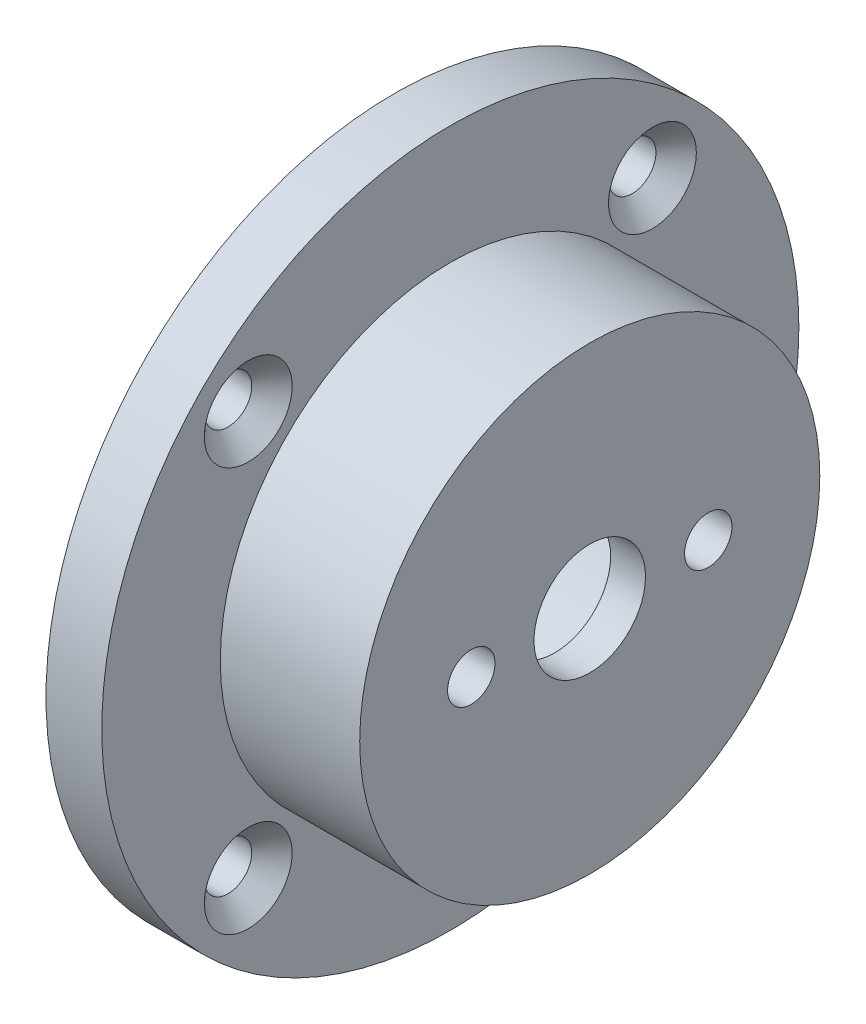
from build123d import *

# Parameters (mm, degrees)
SKETCH1_R                                       = 25
BOSS_EXTRUDE1_DEPTH                             = 4
SKETCH2_R                                       = 16.5
BOSS_EXTRUDE2_DEPTH                             = 10
SKETCH3_R                                       = 12.5
CUT_EXTRUDE1_DEPTH                              = 11.5
SKETCH4_R                                       = 4
CUT_EXTRUDE2_DEPTH                              = 4
M3_CLEARANCE_HOLE1_D                            = 3.4
M3_CLEARANCE_HOLE1_DEPTH                        = 10
CSK_FOR_M3_FLAT_HEAD_MACHINE_SCREW1_D           = 3.4
CSK_FOR_M3_FLAT_HEAD_MACHINE_SCREW1_CSINK_D     = 6.3
CSK_FOR_M3_FLAT_HEAD_MACHINE_SCREW1_CSINK_ANGLE = 90
CIRPATTERN1_COUNT                               = 4
SKETCH10_R                                      = 13.125
CUT_EXTRUDE3_DEPTH                              = 11.5


with BuildPart() as part:
    # Sketch1 → Boss-Extrude1 (new body)
    with BuildSketch(Plane(origin=(0, 0, 0), x_dir=(0, 0, -1), z_dir=(1, 0, 0))):
        Circle(SKETCH1_R)
    extrude(amount=BOSS_EXTRUDE1_DEPTH)

    # Sketch2 → Boss-Extrude2 (add)
    with BuildSketch(Plane(origin=(4, 0, 0), x_dir=(0, 0, -1), z_dir=(1, 0, 0))):
        Circle(SKETCH2_R)
    extrude(amount=BOSS_EXTRUDE2_DEPTH)

    # Sketch3 → Cut-Extrude1 (cut)
    with BuildSketch(Plane.ZY):
        Circle(SKETCH3_R)
    extrude(amount=-CUT_EXTRUDE1_DEPTH, mode=Mode.SUBTRACT)

    # Sketch4 → Cut-Extrude2 (cut)
    with BuildSketch(Plane(origin=(14, 0, 0), x_dir=(0, 0, -1), z_dir=(1, 0, 0))):
        Circle(SKETCH4_R)
    extrude(amount=-CUT_EXTRUDE2_DEPTH, mode=Mode.SUBTRACT)

    # M3 Clearance Hole1
    with Locations(Plane(origin=(14, 0, 0), x_dir=(0, 0, -1), z_dir=(1, 0, 0))):
        with Locations((8.5, 0), (-8.5, 0)):
            Hole(M3_CLEARANCE_HOLE1_D / 2, depth=M3_CLEARANCE_HOLE1_DEPTH)

    # CSK for M3 Flat Head Machine Screw1 (through all)
    with Locations(Plane(origin=(4, 0, 0), x_dir=(0, 0, -1), z_dir=(1, 0, 0))):
        with Locations((-14.495689014, -14.495689014)):
            csk_for_m3_flat_head_machine_screw1 = CounterSinkHole(CSK_FOR_M3_FLAT_HEAD_MACHINE_SCREW1_D / 2, CSK_FOR_M3_FLAT_HEAD_MACHINE_SCREW1_CSINK_D / 2, counter_sink_angle=CSK_FOR_M3_FLAT_HEAD_MACHINE_SCREW1_CSINK_ANGLE)

    # CirPattern1: CSK for M3 Flat Head Machine Screw1 ×4 about axis
    cirpattern1_axis = Axis((0, 0, 0), (1, 0, 0))
    for i in range(1, CIRPATTERN1_COUNT):
        add(csk_for_m3_flat_head_machine_screw1.rotate(cirpattern1_axis, i * 360 / CIRPATTERN1_COUNT), mode=Mode.SUBTRACT)

    # Sketch10 → Cut-Extrude3 (cut)
    with BuildSketch(Plane.ZY):
        Circle(SKETCH10_R)
    extrude(amount=-CUT_EXTRUDE3_DEPTH, mode=Mode.SUBTRACT)


solid = part.part
